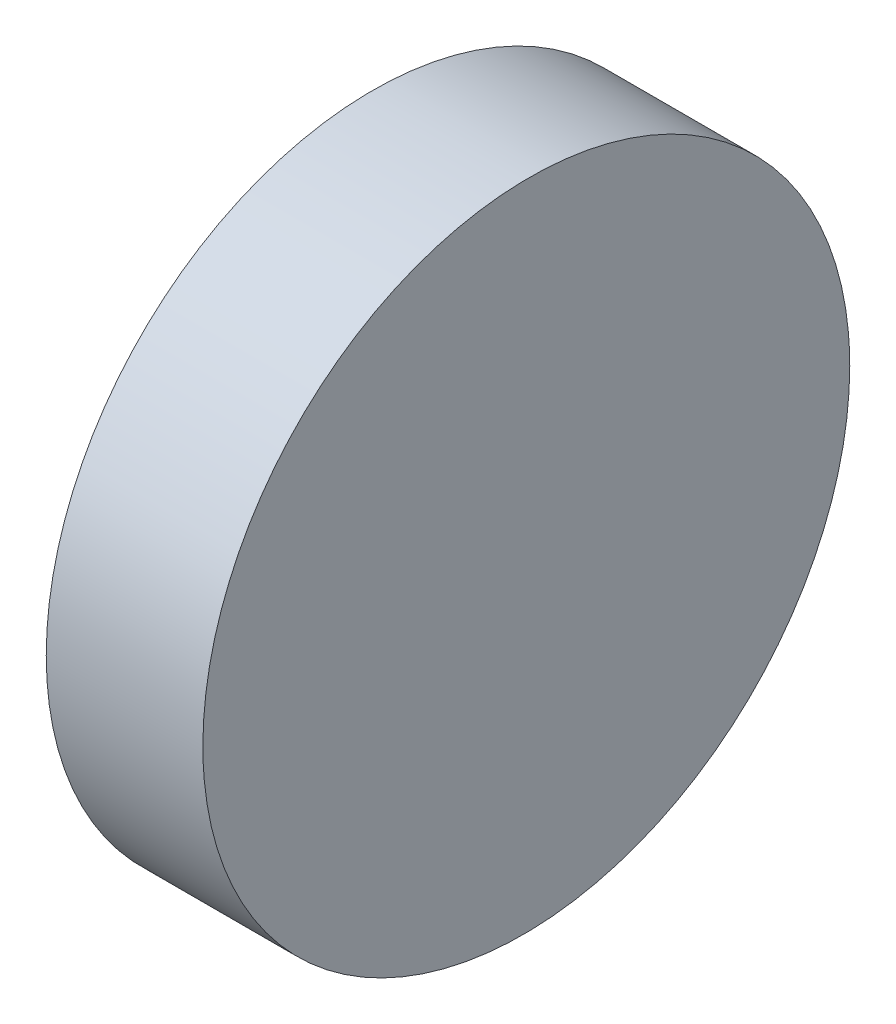
from build123d import *

# Parameters (mm, degrees)
EXTRUDE_1_DEPTH     = 12.5
CUT_EXTRUDE_2_DEPTH = 12.5


with BuildPart() as part:
    # 草图1 → 凸台-拉伸1 (new body)
    with BuildSketch(Plane(origin=(0, 0, 0), x_dir=(1, 0, 0), z_dir=(0, 1, 0))):
        Polygon((0, 6.25), (0, -6.25), (3, -6.25), (2.890914153, 6.25), align=None)
    extrude(amount=EXTRUDE_1_DEPTH)

    # 草图5 → 切除-拉伸2 (cut)
    with BuildSketch(Plane.ZY):
        with BuildLine():
            Line((-6.25, 12.5), (-6.25, 6.25))
            ThreePointArc((-6.25, 6.25), (-4.419417382, 10.669417382), (0, 12.5))
            Line((0, 12.5), (-6.25, 12.5))
        make_face()
        with BuildLine():
            Line((-6.25, 6.25), (-6.25, 0))
            Line((-6.25, 0), (0, 0))
            ThreePointArc((0, 0), (-4.419417382, 1.830582618), (-6.25, 6.25))
        make_face()
        with BuildLine():
            ThreePointArc((6.25, 6.25), (4.419417382, 1.830582618), (0, 0))
            Line((0, 0), (6.25, 0))
            Line((6.25, 0), (6.25, 6.25))
        make_face()
        with BuildLine():
            ThreePointArc((0, 12.5), (4.419417382, 10.669417382), (6.25, 6.25))
            Line((6.25, 6.25), (6.25, 12.5))
            Line((6.25, 12.5), (0, 12.5))
        make_face()
    extrude(amount=-CUT_EXTRUDE_2_DEPTH, mode=Mode.SUBTRACT)


solid = part.part
